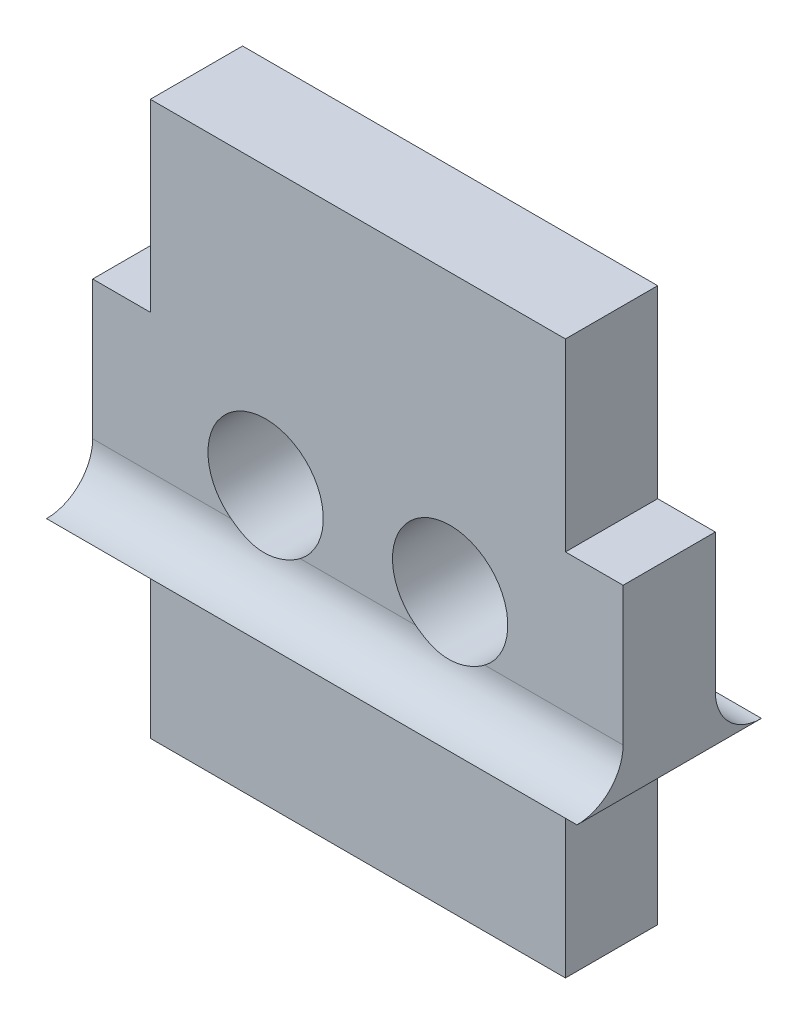
from build123d import *

# Parameters (mm, degrees)
MODEL_R                 = 1.25
BOSS_EXTRUDE1_DEPTH     = 2
BOSS_EXTRUDE2_DEPTH     = 11.50072
SKETCH2_R               = 1.25
CUT_EXTRUDE1_DEPTH      = 2
CUT_EXTRUDE1_DEPTH_BACK = 4


with BuildPart() as part:
    # Model → Boss-Extrude1 (new body)
    with BuildSketch(Plane.XY):
        Polygon((1.25, 4), (0, 4), (0, 8), (1.25, 8), (1.25, 12), (10.25072, 12), (10.25072, 8), (11.50072, 8), (11.50072, 4), (10.25072, 4), (10.25072, 0), (1.25, 0), align=None)
        with Locations((7.75072, 6)):
            Circle(MODEL_R, mode=Mode.SUBTRACT)
        with Locations((3.75, 6)):
            Circle(MODEL_R, mode=Mode.SUBTRACT)
    extrude(amount=BOSS_EXTRUDE1_DEPTH)

    # Sketch1 → Boss-Extrude2 (add)
    with BuildSketch(Plane.ZY):
        with BuildLine():
            Line((2, 4), (2, 5))
            ThreePointArc((2, 5), (2.292893219, 4.292893219), (3, 4))
            Line((3, 4), (2, 4))
        make_face()
        with BuildLine():
            Line((0, 4), (-1, 4))
            ThreePointArc((-1, 4), (-0.292893219, 4.292893219), (0, 5))
            Line((0, 5), (0, 4))
        make_face()
    extrude(amount=-BOSS_EXTRUDE2_DEPTH)

    # Sketch2 → Cut-Extrude1 (cut, two sides)
    with BuildSketch(Plane.XY.offset(2)) as cut_extrude1_sk:
        with Locations((3.75, 6)):
            Circle(SKETCH2_R)
        with Locations((7.75072, 6)):
            Circle(SKETCH2_R)
    extrude(amount=CUT_EXTRUDE1_DEPTH, mode=Mode.SUBTRACT)
    extrude(cut_extrude1_sk.sketch, amount=-CUT_EXTRUDE1_DEPTH_BACK, mode=Mode.SUBTRACT)


solid = part.part
